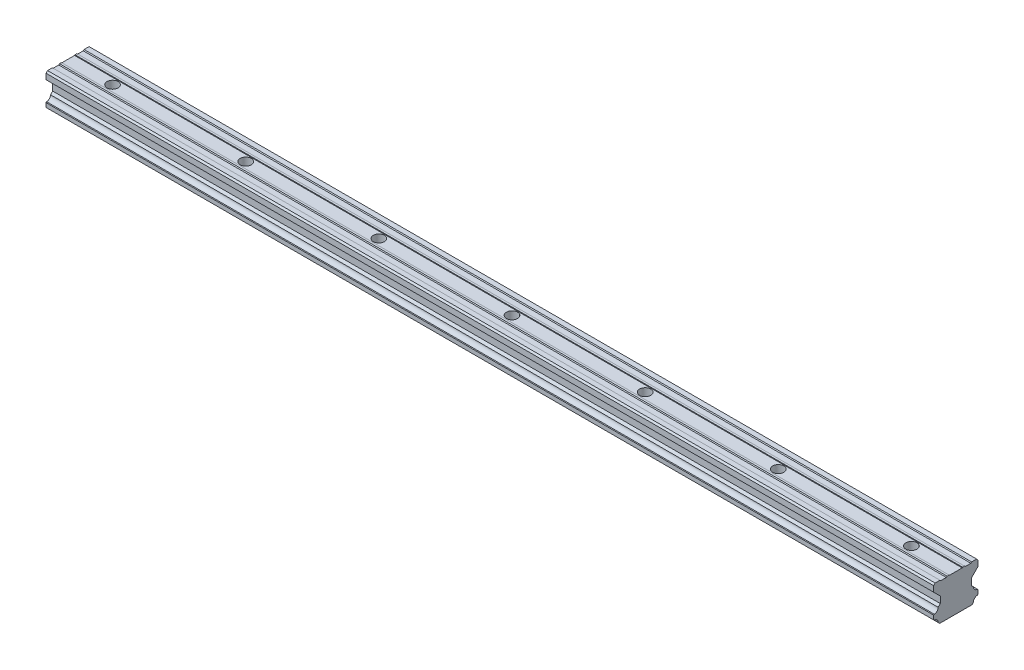
from build123d import *

# Parameters (mm, degrees)
BOSS_EXTRUDE1_DEPTH = 400
HOLE1_D             = 5
HOLE1_CBORE_D       = 9.5
HOLE1_CBORE_DEPTH   = 8.5
LPATTERN1_COUNT     = 7
LPATTERN1_PITCH     = 60


with BuildPart() as part:
    # Sketch1 → Boss-Extrude1 (new body)
    with BuildSketch(Plane(origin=(0, 0, 0), x_dir=(0, 0, -1), z_dir=(1, 0, 0))):
        with BuildLine():
            Line((-7.965754986, -7.693975449), (-7.266272068, -8.393458366))
            Line((-7.266272068, -8.393458366), (7.266272068, -8.393458366))
            Line((7.266272068, -8.393458366), (7.965754986, -7.693975449))
            ThreePointArc((7.965754986, -7.693975449), (8.474723757, -6.421557866), (9.747437917, -5.913331162))
            Line((9.747437917, -5.913331162), (10.000000437, -5.660768637))
            Line((10.000000437, -5.660768637), (10.000000437, -3.788406023))
            Line((10.000000437, -3.788406023), (9.747437912, -3.535843503))
            ThreePointArc((9.747437912, -3.535843503), (8.462742055, -3.016656911), (7.965755402, -1.72321096))
            Line((7.965755402, -1.72321096), (7.005148341, -0.762603918))
            Line((7.005148341, -0.762603918), (7.005148341, 2.166206023))
            Line((7.005148341, 2.166206023), (10.000000347, 5.161058089))
            Line((10.000000347, 5.161058089), (10.000000347, 7.712387211))
            Line((10.000000347, 7.712387211), (9.408464779, 8.393458268))
            Line((9.408464779, 8.393458268), (7.133016457, 8.393458268))
            Line((7.133016457, 8.393458268), (6.789534443, 8.049976247))
            Line((6.789534443, 8.049976247), (4.271139656, 8.049976247))
            Line((4.271139656, 8.049976247), (3.927707784, 8.393458265))
            Line((3.927707784, 8.393458265), (3.061282509, 8.393458265))
            Line((3.061282509, 8.393458265), (2.872049327, 8.204225079))
            Line((2.872049327, 8.204225079), (-2.87204886, 8.204225079))
            Line((-2.87204886, 8.204225079), (-3.061282046, 8.393458261))
            Line((-3.061282046, 8.393458261), (-3.927707321, 8.393458261))
            Line((-3.927707321, 8.393458261), (-4.271189216, 8.049976359))
            Line((-4.271189216, 8.049976359), (-6.789534095, 8.049976359))
            Line((-6.789534095, 8.049976359), (-7.133016116, 8.393458373))
            Line((-7.133016116, 8.393458373), (-9.30771733, 8.393458373))
            Line((-9.30771733, 8.393458373), (-10, 7.70117569))
            Line((-10, 7.70117569), (-10, 5.161058187))
            Line((-10, 5.161058187), (-7.005147934, 2.166206181))
            Line((-7.005147934, 2.166206181), (-7.005147934, -0.76260376))
            Line((-7.005147934, -0.76260376), (-7.965754986, -1.723210812))
            ThreePointArc((-7.965754986, -1.723210812), (-8.462741848, -3.016656549), (-9.747437477, -3.535843372))
            Line((-9.747437477, -3.535843372), (-10, -3.788405895))
            Line((-10, -3.788405895), (-10, -5.660768509))
            Line((-10, -5.660768509), (-9.747437477, -5.913331032))
            ThreePointArc((-9.747437477, -5.913331032), (-8.474723558, -6.421557943), (-7.965754986, -7.693975449))
        make_face()
    extrude(amount=BOSS_EXTRUDE1_DEPTH)

    # Hole1 (through all)
    with Locations(Plane(origin=(20, -8.393458366, 0), x_dir=(0, 0, -1), z_dir=(0, -1, 0))):
        with Locations((0, 0)):
            hole1 = CounterBoreHole(HOLE1_D / 2, HOLE1_CBORE_D / 2, HOLE1_CBORE_DEPTH)

    # LPattern1: Hole1 ×7
    with Locations(*[(i * LPATTERN1_PITCH, 0, 0) for i in range(1, LPATTERN1_COUNT)]):
        add(hole1, mode=Mode.SUBTRACT)


solid = part.part
